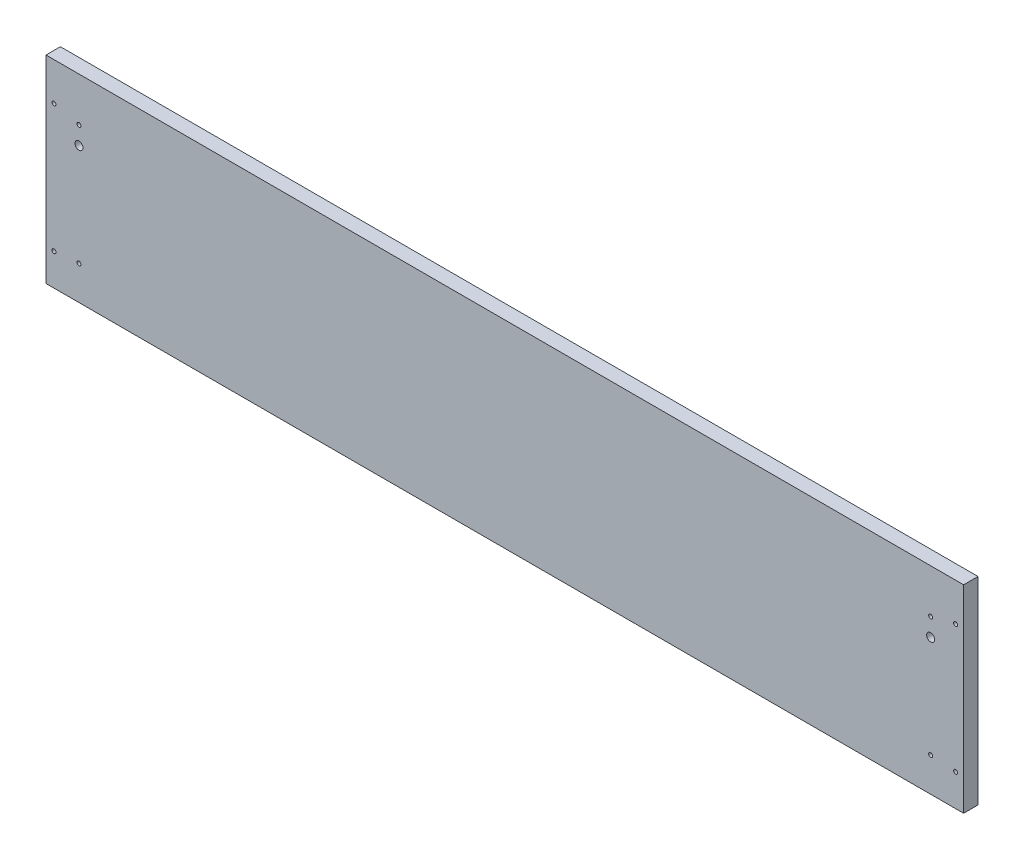
from build123d import *

# Parameters (mm, degrees)
LIDOUTLINE_W               = 728.6625
LIDOUTLINE_H               = 157.1625
LIDOUTLINE_THICKNESS_DEPTH = 11.43
LID_MOUNTINGHOLES_R        = 3.175
LID_MOUNTINGHOLES_R_2      = 1.5875
CUT_EXTRUDE1_DEPTH         = 11.43


with BuildPart() as part:
    # LidOutline → LidOutline_Thickness (new body)
    with BuildSketch(Plane.XY):
        with Locations((-5376.06875, 1285.08125)):
            Rectangle(LIDOUTLINE_W, LIDOUTLINE_H)
    extrude(amount=-LIDOUTLINE_THICKNESS_DEPTH)

    # Lid_MountingHoles → Cut-Extrude1 (cut)
    with BuildSketch(Plane.XY):
        with Locations((-5714.20625, 1314.45)):
            Circle(LID_MOUNTINGHOLES_R)
        with Locations((-5714.20625, 1328.7375)):
            Circle(LID_MOUNTINGHOLES_R_2)
        with Locations((-5734.05, 1333.5)):
            Circle(LID_MOUNTINGHOLES_R_2)
        with Locations((-5734.05, 1231.9)):
            Circle(LID_MOUNTINGHOLES_R_2)
        with Locations((-5714.20625, 1233.4875)):
            Circle(LID_MOUNTINGHOLES_R_2)
        with Locations((-5037.93125, 1314.45)):
            Circle(LID_MOUNTINGHOLES_R)
        with Locations((-5037.93125, 1328.7375)):
            Circle(LID_MOUNTINGHOLES_R_2)
        with Locations((-5018.0875, 1333.5)):
            Circle(LID_MOUNTINGHOLES_R_2)
        with Locations((-5037.93125, 1233.4875)):
            Circle(LID_MOUNTINGHOLES_R_2)
        with Locations((-5018.0875, 1231.9)):
            Circle(LID_MOUNTINGHOLES_R_2)
    extrude(amount=-CUT_EXTRUDE1_DEPTH, mode=Mode.SUBTRACT)


solid = part.part
